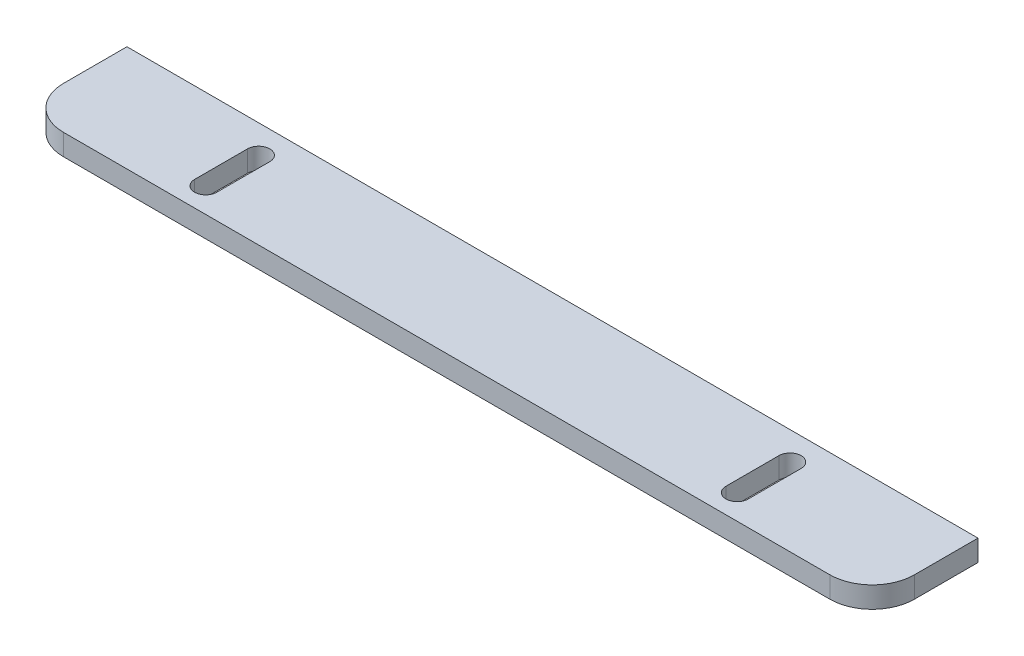
from build123d import *

# Parameters (mm, degrees)
SALIENTE_EXTRUIR1_DEPTH = 5


with BuildPart() as part:
    # Croquis1 → Saliente-Extruir1 (new body)
    with BuildSketch(Plane(origin=(0, 0, 0), x_dir=(1, 0, 0), z_dir=(0, 1, 0))):
        with BuildLine():
            Line((10, 0), (191, 0))
            ThreePointArc((191, 0), (198.071067812, 2.928932188), (201, 10))
            Line((201, 10), (201, 25))
            Line((201, 25), (0, 25))
            Line((0, 25), (0, 10))
            ThreePointArc((0, 10), (2.928932188, 2.928932188), (10, 0))
        make_face()
        with BuildLine():
            Line((40.375, 18.359540636), (40.375, 5.859540636))
            ThreePointArc((40.375, 5.859540636), (37.75, 3.234540636), (35.125, 5.859540636))
            Line((35.125, 5.859540636), (35.125, 18.359540636))
            ThreePointArc((35.125, 18.359540636), (37.75, 20.984540636), (40.375, 18.359540636))
        make_face(mode=Mode.SUBTRACT)
        with BuildLine():
            Line((160.625, 18.359540636), (160.625, 5.859540636))
            ThreePointArc((160.625, 5.859540636), (163.25, 3.234540636), (165.875, 5.859540636))
            Line((165.875, 5.859540636), (165.875, 18.359540636))
            ThreePointArc((165.875, 18.359540636), (163.25, 20.984540636), (160.625, 18.359540636))
        make_face(mode=Mode.SUBTRACT)
    extrude(amount=SALIENTE_EXTRUIR1_DEPTH)


solid = part.part
